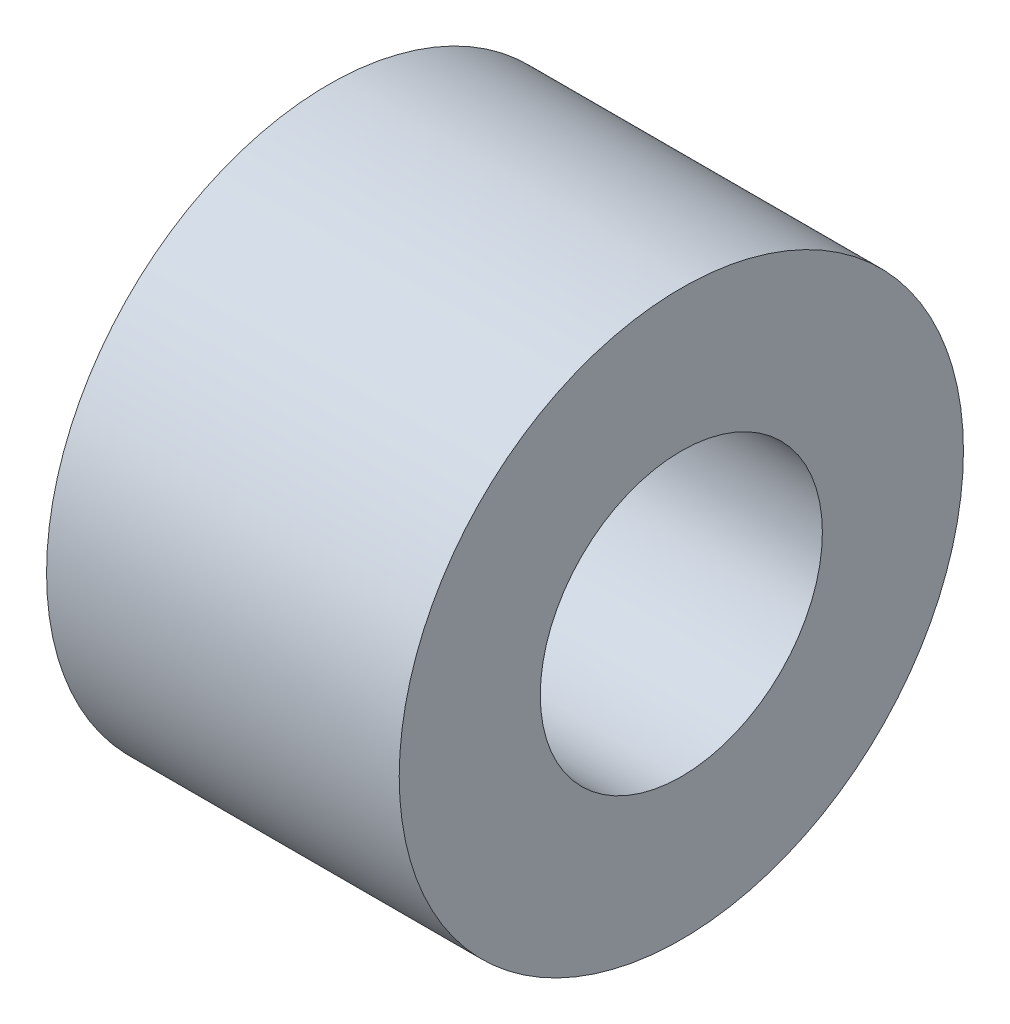
from build123d import *

# Parameters (mm, degrees)
SKETCH1_W = 5
SKETCH1_H = 2


with BuildPart() as part:
    # Sketch1 → Revolve1 (revolve)
    with BuildSketch(Plane.XY):
        with Locations((2.5, -3)):
            Rectangle(SKETCH1_W, SKETCH1_H)
    revolve(axis=Axis((0, 0, 0), (1, 0, 0)))


solid = part.part
